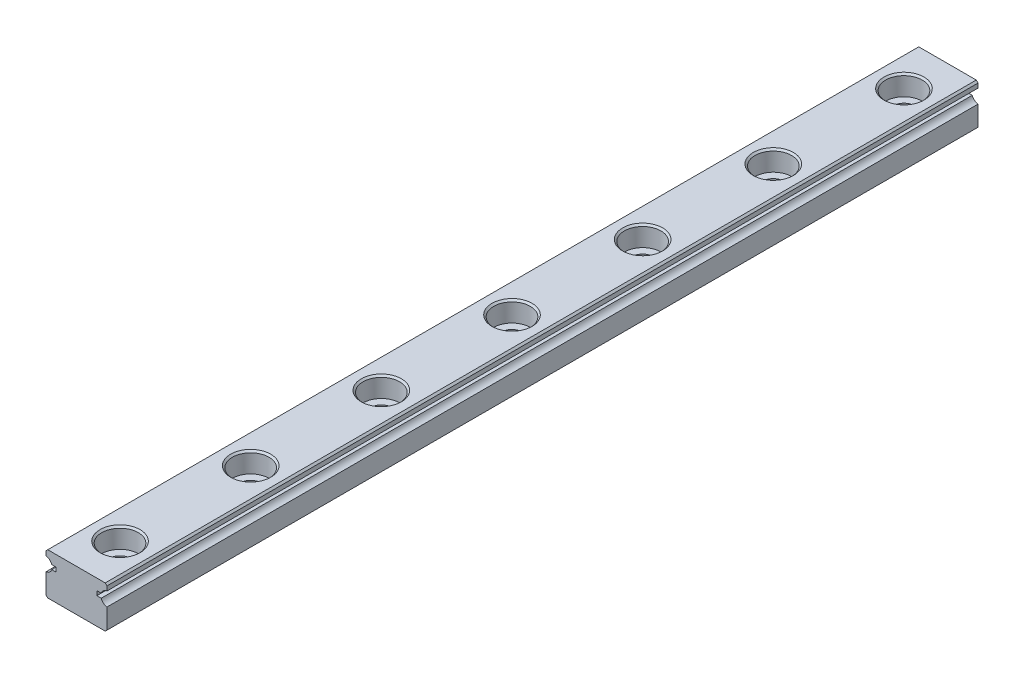
from build123d import *

# Parameters (mm, degrees)
EXTRUDE1_DEPTH             = 100
EXTRUDE2_REACH             = 102.176
SKETCH2_R                  = 1.2
SKETCH_R                   = 2.1
SKETCH_R_2                 = 1.2
EXTRUDE4_DEPTH             = 2.3
CHAMFER1_SIZE              = 0.2
LPATTERN1_COUNT            = 7
LPATTERN1_PITCH            = 15
CHAMFER1_OF_LPATTERN1_SIZE = 0.2


with BuildPart() as part:
    # Sketch1 → Extrude1 (new body)
    with BuildSketch(Plane.XY):
        with BuildLine():
            Line((-3.3, -2.4), (3.3, -2.4))
            Line((3.3, -2.4), (3.5, -2.2))
            Line((3.5, -2.2), (3.5, 0.106274607))
            ThreePointArc((3.5, 0.106274607), (3.091294745, 0.282570681), (2.840065792, 0.65))
            Line((2.840065792, 0.65), (2.340065792, 0.65))
            Line((2.340065792, 0.65), (2.340065792, 1.15))
            Line((2.340065792, 1.15), (2.840065792, 1.15))
            ThreePointArc((2.840065792, 1.15), (3.091294745, 1.517429319), (3.5, 1.693725393))
            Line((3.5, 1.693725393), (3.5, 2.2))
            Line((3.5, 2.2), (3.3, 2.4))
            Line((3.3, 2.4), (-3.3, 2.4))
            Line((-3.3, 2.4), (-3.5, 2.2))
            Line((-3.5, 2.2), (-3.5, 1.693725393))
            ThreePointArc((-3.5, 1.693725393), (-3.091294745, 1.517429319), (-2.840065792, 1.15))
            Line((-2.840065792, 1.15), (-2.340065792, 1.15))
            Line((-2.340065792, 1.15), (-2.340065792, 0.65))
            Line((-2.340065792, 0.65), (-2.840065792, 0.65))
            ThreePointArc((-2.840065792, 0.65), (-3.091294745, 0.282570681), (-3.5, 0.106274607))
            Line((-3.5, 0.106274607), (-3.5, -2.2))
            Line((-3.5, -2.2), (-3.3, -2.4))
        make_face()
    extrude(amount=EXTRUDE1_DEPTH)

    # Sketch2 → Extrude2 (cut, up to next)
    with BuildSketch(Plane(origin=(0, 2.4, 0), x_dir=(1, 0, 0), z_dir=(0, 1, 0)), mode=Mode.PRIVATE) as extrude2_sk1:
        with Locations((0, -5)):
            Circle(SKETCH2_R)
    extrude2_tool1 = extrude(extrude2_sk1.sketch, amount=-EXTRUDE2_REACH, mode=Mode.PRIVATE) & part.part
    extrude2 = extrude2_tool1.solids().sort_by_distance((0, 2.4, 5))[0]
    add(extrude2, mode=Mode.SUBTRACT)

    # Sketch → Extrude4 (cut)
    with BuildSketch(Plane(origin=(0, 2.4, 0), x_dir=(1, 0, 0), z_dir=(0, 1, 0))):
        with Locations((0, -5)):
            Circle(SKETCH_R)
        with Locations((0, -5)):
            Circle(SKETCH_R_2, mode=Mode.SUBTRACT)
    extrude4 = extrude(amount=-EXTRUDE4_DEPTH, mode=Mode.SUBTRACT)

    # Chamfer1
    chamfer1_edges = [part.edges().sort_by_distance(p)[0] for p in [
        (-1.2, -2.4, 5),
        (-2.1, 2.4, 5),
    ]]
    chamfer(chamfer1_edges, length=CHAMFER1_SIZE)

    # LPattern1: Extrude2, Extrude4 ×7
    with Locations(*[(0, 0, i * LPATTERN1_PITCH) for i in range(1, LPATTERN1_COUNT)]):
        add(extrude2, mode=Mode.SUBTRACT)
        add(extrude4, mode=Mode.SUBTRACT)

    # Chamfer1 of LPattern1
    chamfer1_of_lpattern1_edges = [part.edges().sort_by_distance(p)[0] for p in [
        (-1.2, -2.4, 20),
        (-2.1, 2.4, 20),
        (-1.2, -2.4, 35),
        (-2.1, 2.4, 35),
        (-1.2, -2.4, 50),
        (-2.1, 2.4, 50),
        (-1.2, -2.4, 65),
        (-2.1, 2.4, 65),
        (-1.2, -2.4, 80),
        (-2.1, 2.4, 80),
        (-1.2, -2.4, 95),
        (-2.1, 2.4, 95),
    ]]
    chamfer(chamfer1_of_lpattern1_edges, length=CHAMFER1_OF_LPATTERN1_SIZE)


solid = part.part
